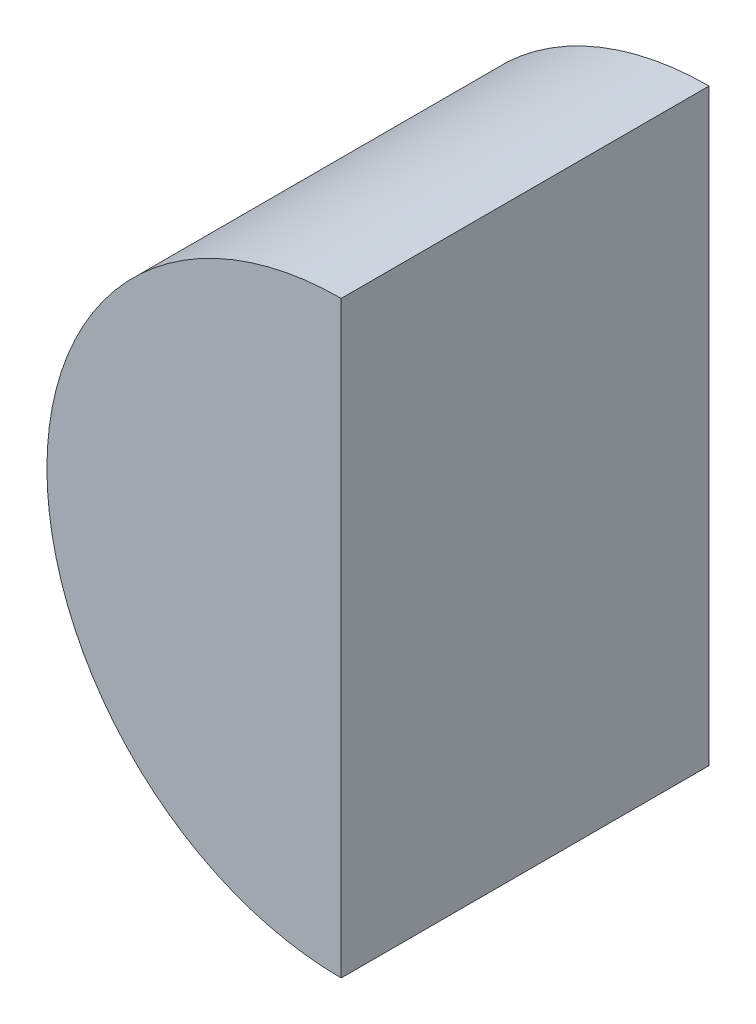
from build123d import *

# Parameters (mm, degrees)
BOSS_EXTRUDE1_DEPTH = 25


with BuildPart() as part:
    # Sketch1 → Boss-Extrude1 (new body)
    with BuildSketch(Plane.XY):
        with BuildLine():
            Line((-250, 232.5), (-250, 192.5))
            ThreePointArc((-250, 192.5), (-270, 212.5), (-250, 232.5))
        make_face()
    extrude(amount=-BOSS_EXTRUDE1_DEPTH)


solid = part.part
